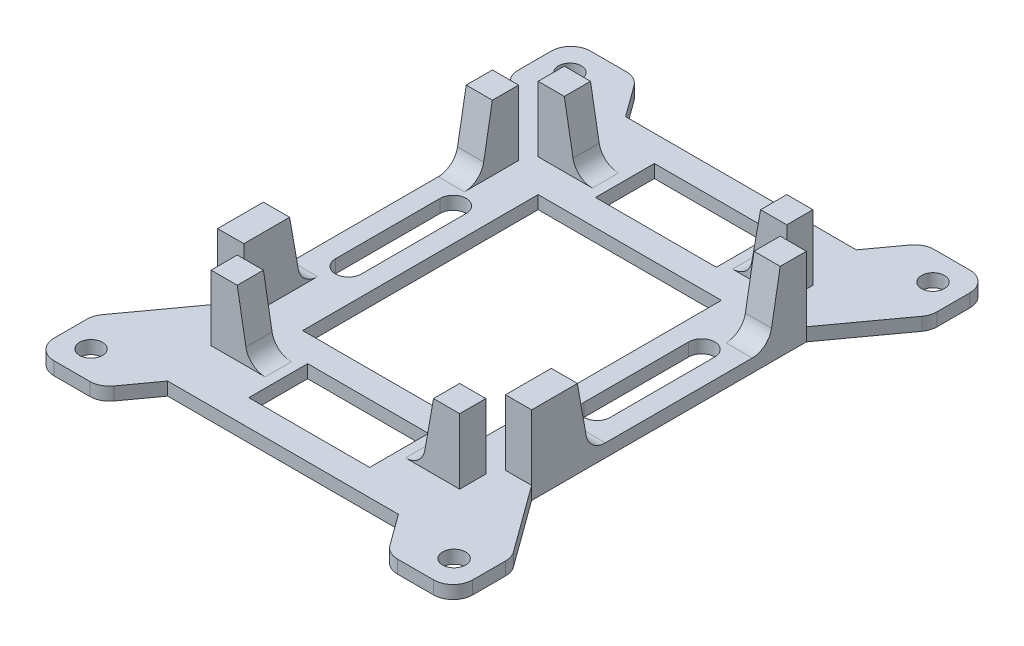
from build123d import *

# Parameters (mm, degrees)
SKETCH1_W           = 64
SKETCH1_H           = 82
SKETCH1_R           = 1.75
SKETCH1_W_2         = 28
SKETCH1_H_2         = 36
BOSS_EXTRUDE1_DEPTH = 2
SKETCH4_W           = 4
SKETCH4_H           = 4
SKETCH4_H_2         = 7
BOSS_EXTRUDE2_DEPTH = 10
CUT_EXTRUDE1_DEPTH  = 3
DRAFT12_ANGLE       = 10
DRAFT13_ANGLE       = 10
SKETCH6_W           = 18.473460386
SKETCH6_H           = 9
CUT_EXTRUDE2_DEPTH  = 3
FILLET1_R           = 3
FILLET2_R           = 3


with BuildPart() as part:
    # Sketch1 → Boss-Extrude1 (new body)
    with BuildSketch(Plane(origin=(0, 0, 0), x_dir=(1, 0, 0), z_dir=(0, 1, 0))):
        Rectangle(SKETCH1_W, SKETCH1_H)
        with Locations((27.75, -36.6)):
            Circle(SKETCH1_R, mode=Mode.SUBTRACT)
        with Locations((-27.75, -36.6)):
            Circle(SKETCH1_R, mode=Mode.SUBTRACT)
        with Locations((-27.75, 36.6)):
            Circle(SKETCH1_R, mode=Mode.SUBTRACT)
        with Locations((27.75, 36.6)):
            Circle(SKETCH1_R, mode=Mode.SUBTRACT)
        Rectangle(SKETCH1_W_2, SKETCH1_H_2, mode=Mode.SUBTRACT)
    extrude(amount=BOSS_EXTRUDE1_DEPTH)

    # Sketch4 → Boss-Extrude2 (add)
    with BuildSketch(Plane(origin=(0, 2, 0), x_dir=(1, 0, 0), z_dir=(0, 1, 0))):
        with Locations((-17, -25)):
            Rectangle(SKETCH4_W, SKETCH4_H)
        with Locations((17, -25)):
            Rectangle(SKETCH4_W, SKETCH4_H)
        with Locations((-17, 25)):
            Rectangle(SKETCH4_W, SKETCH4_H)
        with Locations((17, 25)):
            Rectangle(SKETCH4_W, SKETCH4_H)
        with Locations((-22, -17.5)):
            Rectangle(SKETCH4_W, SKETCH4_H_2)
        with Locations((22, -17.5)):
            Rectangle(SKETCH4_W, SKETCH4_H_2)
        with Locations((-22, 19)):
            Rectangle(SKETCH4_W, SKETCH4_H)
        with Locations((22, 19)):
            Rectangle(SKETCH4_W, SKETCH4_H)
    extrude(amount=BOSS_EXTRUDE2_DEPTH)

    # Sketch5 → Cut-Extrude1 (cut, through all)
    with BuildSketch(Plane(origin=(0, 2, 0), x_dir=(1, 0, 0), z_dir=(0, 1, 0))):
        Polygon((-32, 32), (-24, 21), (-24, -21), (-32, -32), align=None)
        Polygon((32, -32), (24, -21), (24, 21), (32, 32), align=None)
    extrude(amount=-CUT_EXTRUDE1_DEPTH, mode=Mode.SUBTRACT)

    # Draft12
    draft12_faces = [part.faces().sort_by_distance(p)[0] for p in [
        (22, 7, 14),
        (22, 7, -17),
        (-22, 7, 14),
        (-22, 7, -17),
    ]]
    draft(draft12_faces, Plane.ZX.offset(12), DRAFT12_ANGLE)

    # Draft13
    draft13_faces = [part.faces().sort_by_distance(p)[0] for p in [
        (15, 7, 25),
        (-15, 7, 25),
        (15, 7, -25),
        (-15, 7, -25),
    ]]
    draft(draft13_faces, Plane.ZX.offset(12), DRAFT13_ANGLE)

    # Sketch6 → Cut-Extrude2 (cut, through all)
    with BuildSketch(Plane(origin=(0, 2, 0), x_dir=(1, 0, 0), z_dir=(0, 1, 0))):
        Polygon((-22, 41), (-17.636363636, 35), (17.636363636, 35), (22, 41), align=None)
        with BuildLine():
            Line((17, 10), (17, -6))
            ThreePointArc((17, -6), (19, -8), (21, -6))
            Line((21, -6), (21, 10))
            ThreePointArc((21, 10), (19, 12), (17, 10))
        make_face()
        Polygon((22, -41), (17.636363636, -35), (-17.636363636, -35), (-22, -41), align=None)
        with Locations((0, 26.5)):
            Rectangle(SKETCH6_W, SKETCH6_H)
        with Locations((0, -26.5)):
            Rectangle(SKETCH6_W, SKETCH6_H)
        with BuildLine():
            Line((-17, 10), (-17, -6))
            ThreePointArc((-17, -6), (-19, -8), (-21, -6))
            Line((-21, -6), (-21, 10))
            ThreePointArc((-21, 10), (-19, 12), (-17, 10))
        make_face()
    extrude(amount=-CUT_EXTRUDE2_DEPTH, mode=Mode.SUBTRACT)

    # Fillet1
    fillet1_edges = [part.edges().sort_by_distance(p)[0] for p in [
        (-32, 1, 32),
        (-32, 1, -32),
        (32, 1, -32),
        (32, 1, 32),
        (-22, 1, -41),
        (22, 1, -41),
        (22, 1, 41),
        (-22, 1, 41),
        (32, 1, 41),
        (-32, 1, 41),
        (-32, 1, -41),
        (32, 1, -41),
    ]]
    fillet(fillet1_edges, radius=FILLET1_R)

    # Fillet2
    fillet2_edges = [part.edges().sort_by_distance(p)[0] for p in [
        (-22, 2, 12.236730193),
        (22, 2, -15.236730193),
        (-22, 2, -15.236730193),
        (13.236730193, 2, 25),
        (-13.236730193, 2, 25),
        (-13.236730193, 2, -25),
        (13.236730193, 2, -25),
        (22, 2, 12.236730193),
    ]]
    fillet(fillet2_edges, radius=FILLET2_R)


solid = part.part
